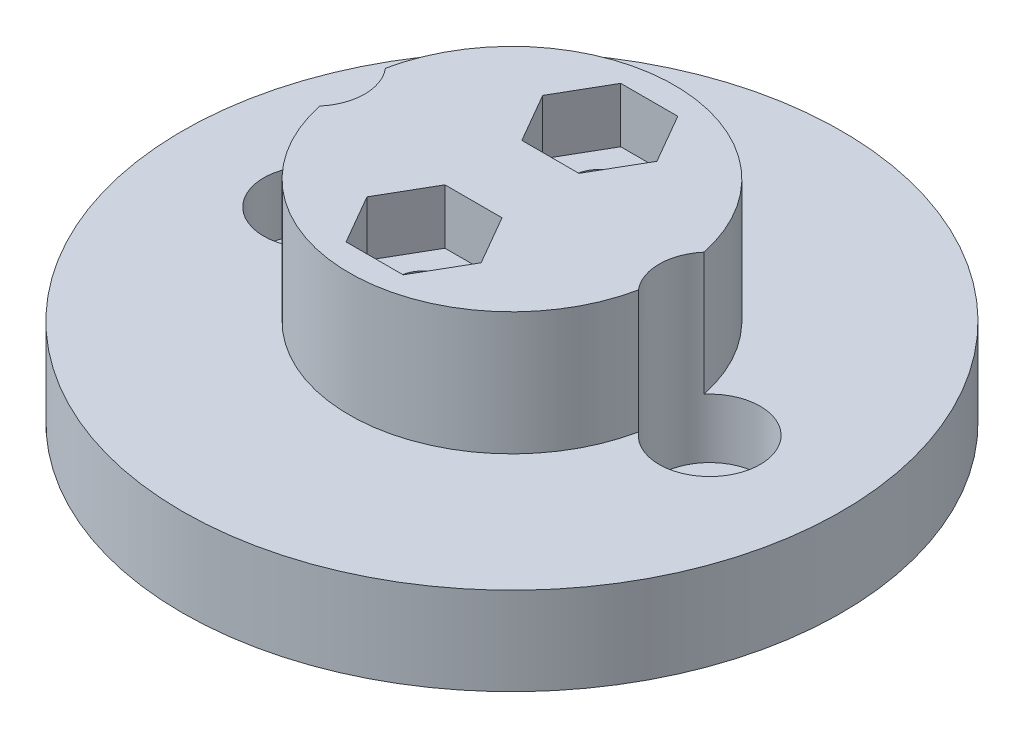
from build123d import *

# Parameters (mm, degrees)
SKETCH1_R               = 19.05
BOSS_EXTRUDE1_DEPTH     = 5.08
SKETCH4_R               = 9.398
BOSS_EXTRUDE2_DEPTH     = 7.112
SKETCH5_R               = 2.921
CUT_EXTRUDE1_DEPTH      = 28.863695807
CUT_EXTRUDE1_DEPTH_BACK = 3.429
SKETCH6_R               = 1.4605
SKETCH6_R_2             = 1.73706236
CUT_EXTRUDE2_DEPTH      = 28.863695807
CUT_EXTRUDE2_DEPTH_BACK = 28.863695807
CUT_EXTRUDE5_DEPTH      = 3.175
SKETCH10_R              = 1.5875
CUT_EXTRUDE6_DEPTH      = 7.62


with BuildPart() as part:
    # Sketch1 → Boss-Extrude1 (new body)
    with BuildSketch(Plane(origin=(0, 0, 0), x_dir=(1, 0, 0), z_dir=(0, 1, 0))):
        with Locations(Location((0, 0, 0), (0, 0, 270))):
            Circle(SKETCH1_R)
    extrude(amount=BOSS_EXTRUDE1_DEPTH)

    # Sketch4 → Boss-Extrude2 (add)
    with BuildSketch(Plane(origin=(0, 5.08, 0), x_dir=(1, 0, 0), z_dir=(0, 1, 0))):
        with Locations(Location((0, 0, 0), (0, 0, 270))):
            Circle(SKETCH4_R)
    extrude(amount=BOSS_EXTRUDE2_DEPTH)

    # Sketch5 → Cut-Extrude1 (cut, two sides)
    with BuildSketch(Plane(origin=(0, 5.08, 0), x_dir=(1, 0, 0), z_dir=(0, 1, 0))) as cut_extrude1_sk:
        with Locations(Location((-11.43, 0, 0), (0, 0, 40.395058429))):
            Circle(SKETCH5_R)
        with Locations(Location((11.43, 0, 0), (0, 0, 139.604941571))):
            Circle(SKETCH5_R)
    extrude(amount=CUT_EXTRUDE1_DEPTH, mode=Mode.SUBTRACT)
    extrude(cut_extrude1_sk.sketch, amount=-CUT_EXTRUDE1_DEPTH_BACK, mode=Mode.SUBTRACT)

    # Sketch6 → Cut-Extrude2 (cut, two sides)
    with BuildSketch(Plane(origin=(0, 5.08, 0), x_dir=(1, 0, 0), z_dir=(0, 1, 0))) as cut_extrude2_sk:
        with Locations(Location((-11.43, 0, 0), (0, 0, 270))):
            Circle(SKETCH6_R)
        with Locations(Location((11.43, 0, 0), (0, 0, 270))):
            Circle(SKETCH6_R_2)
    extrude(amount=CUT_EXTRUDE2_DEPTH, mode=Mode.SUBTRACT)
    extrude(cut_extrude2_sk.sketch, amount=-CUT_EXTRUDE2_DEPTH_BACK, mode=Mode.SUBTRACT)

    # Sketch9 → Cut-Extrude5 (cut)
    with BuildSketch(Plane(origin=(0, 12.192, 0), x_dir=(1, 0, 0), z_dir=(0, 1, 0))):
        Polygon((3.299556788, 5.08), (1.649778394, 7.9375), (-1.649778394, 7.9375), (-3.299556788, 5.08), (-1.649778394, 2.2225), (1.649778394, 2.2225), align=None)
        Polygon((3.299556788, -5.08), (1.649778394, -2.2225), (-1.649778394, -2.2225), (-3.299556788, -5.08), (-1.649778394, -7.9375), (1.649778394, -7.9375), align=None)
    extrude(amount=-CUT_EXTRUDE5_DEPTH, mode=Mode.SUBTRACT)

    # Sketch10 → Cut-Extrude6 (cut)
    with BuildSketch(Plane(origin=(0, 12.192, 0), x_dir=(1, 0, 0), z_dir=(0, 1, 0))):
        with Locations(Location((0, 5.08, 0), (0, 0, 270))):
            Circle(SKETCH10_R)
        with Locations(Location((0, -5.08, 0), (0, 0, 270))):
            Circle(SKETCH10_R)
    extrude(amount=-CUT_EXTRUDE6_DEPTH, mode=Mode.SUBTRACT)


solid = part.part
